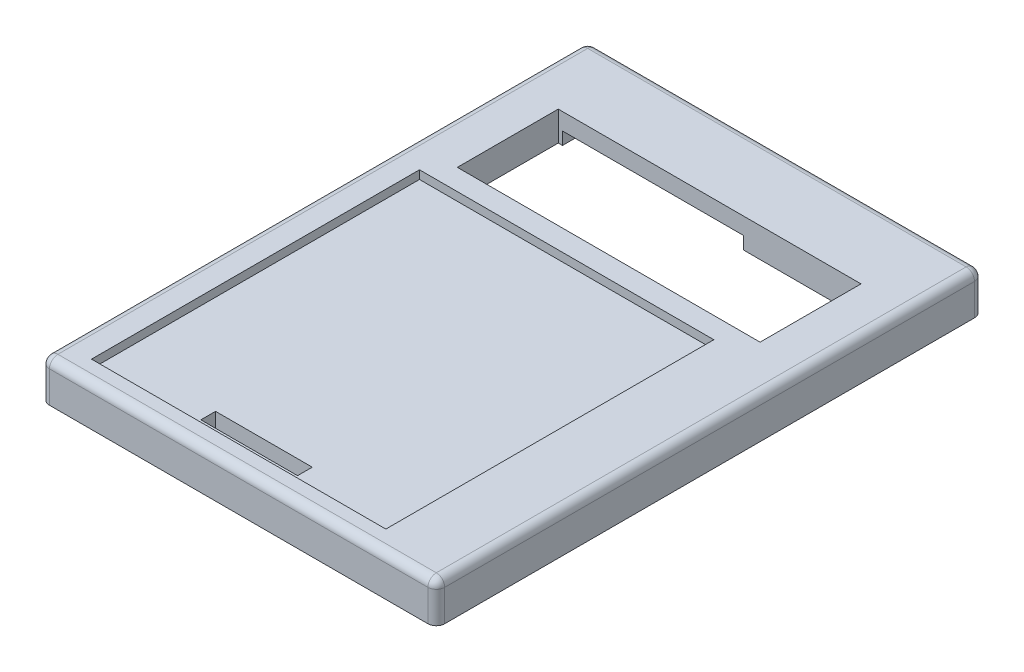
from build123d import *

# Parameters (mm, degrees)
SKETCH1_W           = 94
SKETCH1_H           = 130
BOSS_EXTRUDE1_DEPTH = 7
SKETCH2_W           = 72
SKETCH2_H           = 24
CUT_EXTRUDE1_DEPTH  = 8
SKETCH3_W           = 6
SKETCH3_H           = 18
CUT_EXTRUDE2_DEPTH  = 3.5
SKETCH4_W           = 43
SKETCH4_H           = 7.5
CUT_EXTRUDE3_DEPTH  = 3
SKETCH5_W           = 70
SKETCH5_H           = 78
CUT_EXTRUDE4_DEPTH  = 2
SKETCH6_W           = 23
SKETCH6_H           = 3.5
CUT_EXTRUDE5_DEPTH  = 6
FILLET1_R           = 2
SKETCH8_W           = 90.5
SKETCH8_H           = 126.5
BOSS_EXTRUDE2_DEPTH = 2.5


with BuildPart() as part:
    # Sketch1 → Boss-Extrude1 (new body)
    with BuildSketch(Plane(origin=(0, 0, 0), x_dir=(1, 0, 0), z_dir=(0, 1, 0))):
        with Locations((47, 65)):
            Rectangle(SKETCH1_W, SKETCH1_H)
    extrude(amount=BOSS_EXTRUDE1_DEPTH)

    # Sketch2 → Cut-Extrude1 (cut, through all)
    with BuildSketch(Plane(origin=(0, 7, 0), x_dir=(1, 0, 0), z_dir=(0, 1, 0))):
        with Locations((47, 100)):
            Rectangle(SKETCH2_W, SKETCH2_H)
    extrude(amount=-CUT_EXTRUDE1_DEPTH, mode=Mode.SUBTRACT)

    # Sketch3 → Cut-Extrude2 (cut)
    with BuildSketch(Plane.XZ):
        with Locations((86, -100)):
            Rectangle(SKETCH3_W, SKETCH3_H)
    extrude(amount=-CUT_EXTRUDE2_DEPTH, mode=Mode.SUBTRACT)

    # Sketch4 → Cut-Extrude3 (cut)
    with BuildSketch(Plane.XZ):
        with Locations((33.5, -115.75)):
            Rectangle(SKETCH4_W, SKETCH4_H)
    extrude(amount=-CUT_EXTRUDE3_DEPTH, mode=Mode.SUBTRACT)

    # Sketch5 → Cut-Extrude4 (cut)
    with BuildSketch(Plane(origin=(0, 7, 0), x_dir=(1, 0, 0), z_dir=(0, 1, 0))):
        with Locations((42, 44)):
            Rectangle(SKETCH5_W, SKETCH5_H)
    extrude(amount=-CUT_EXTRUDE4_DEPTH, mode=Mode.SUBTRACT)

    # Sketch6 → Cut-Extrude5 (cut, through all)
    with BuildSketch(Plane(origin=(0, 5, 0), x_dir=(1, 0, 0), z_dir=(0, 1, 0))):
        with Locations((42, 9.25)):
            Rectangle(SKETCH6_W, SKETCH6_H)
    extrude(amount=-CUT_EXTRUDE5_DEPTH, mode=Mode.SUBTRACT)

    # Fillet1
    fillet1_edges = [part.edges().sort_by_distance(p)[0] for p in [
        (94, 7, -65),
        (47, 7, -130),
        (0, 7, -65),
        (0, 3.5, -130),
        (94, 3.5, -130),
        (94, 3.5, 0),
        (0, 3.5, 0),
        (47, 7, 0),
    ]]
    fillet(fillet1_edges, radius=FILLET1_R)

    # Sketch8 → Boss-Extrude2 (add)
    with BuildSketch(Plane.XZ):
        with BuildLine():
            Line((92, -130), (2, -130))
            ThreePointArc((2, -130), (0.585786438, -129.414213562), (0, -128))
            Line((0, -128), (0, -2))
            ThreePointArc((0, -2), (0.585786438, -0.585786438), (2, 0))
            Line((2, 0), (92, 0))
            ThreePointArc((92, 0), (93.414213562, -0.585786438), (94, -2))
            Line((94, -2), (94, -128))
            ThreePointArc((94, -128), (93.414213562, -129.414213562), (92, -130))
        make_face()
        with Locations((47, -65)):
            Rectangle(SKETCH8_W, SKETCH8_H, mode=Mode.SUBTRACT)
    extrude(amount=BOSS_EXTRUDE2_DEPTH)


solid = part.part
